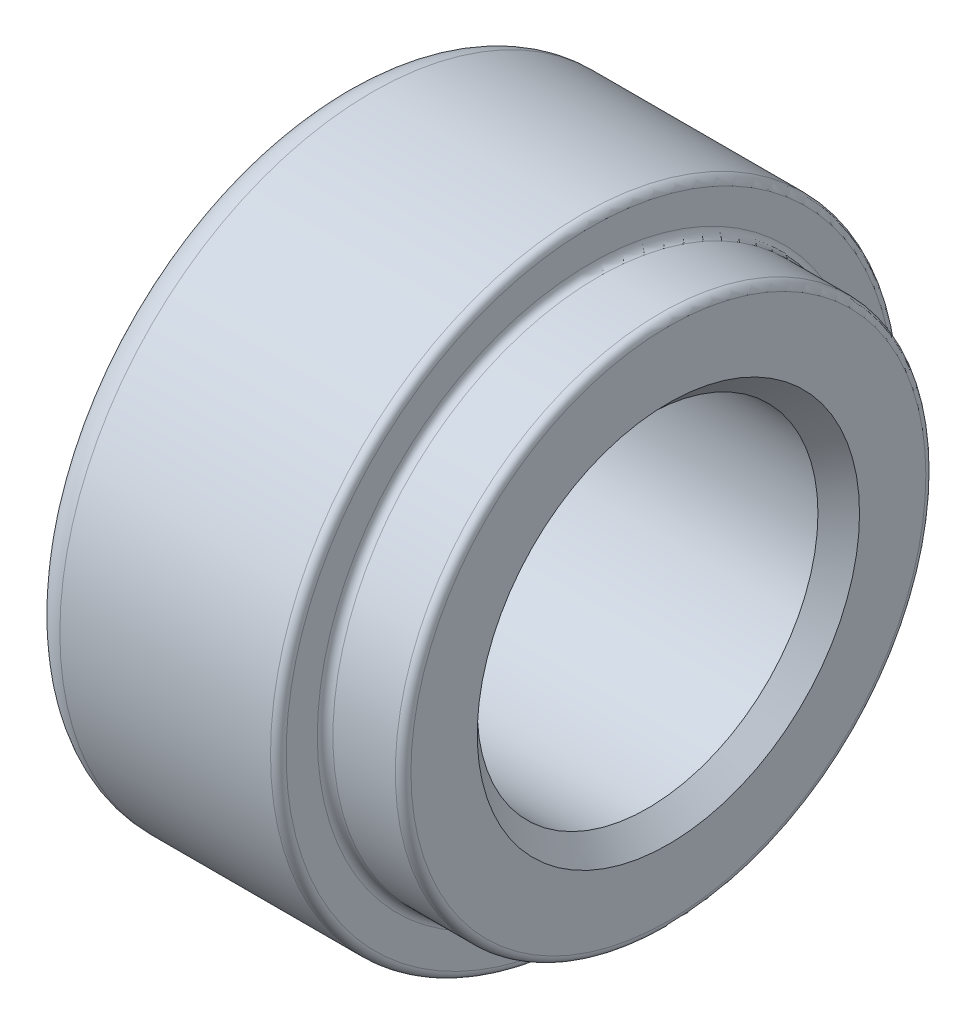
from build123d import *


with BuildPart() as part:
    # Sketch1 → Base-Revolve (revolve)
    with BuildSketch(Plane.XY):
        with BuildLine():
            Line((0, 12.25), (0, 16.5))
            ThreePointArc((0, 16.5), (-0.146446609, 16.853553391), (-0.5, 17))
            Line((-0.5, 17), (-4.5, 17))
            ThreePointArc((-4.5, 17), (-4.853553391, 17.146446609), (-5, 17.5))
            Line((-5, 17.5), (-5, 19.5))
            ThreePointArc((-5, 19.5), (-5.146446609, 19.853553391), (-5.5, 20))
            Line((-5.5, 20), (-19, 20))
            ThreePointArc((-19, 20), (-20.414213562, 19.414213562), (-21, 18))
            Line((-21, 18), (-21, 12.25))
            Line((-21, 12.25), (-19.6675, 10.9175))
            Line((-19.6675, 10.9175), (-1.3325, 10.9175))
            Line((-1.3325, 10.9175), (0, 12.25))
        make_face()
    revolve(axis=Axis((0, 0, 0), (-1, 0, 0)))


solid = part.part
